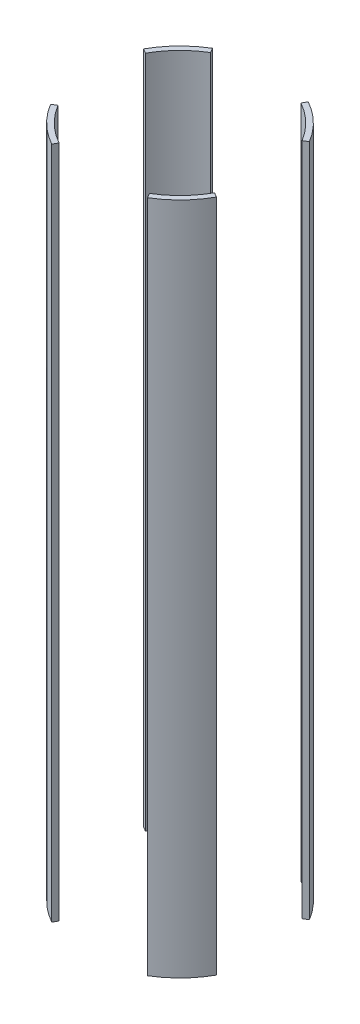
from build123d import *

# Parameters (mm, degrees)
SKETCH2_R               = 88.9
SKETCH2_R_2             = 83.82
BOSS_EXTRUDE1_DEPTH     = 317.5
CUT_EXTRUDE1_DEPTH      = 318.5
CUT_EXTRUDE1_DEPTH_BACK = 318.5


with BuildPart() as part:
    # Sketch2 → Boss-Extrude1 (new body, symmetric)
    with BuildSketch(Plane(origin=(0, 0, 0), x_dir=(1, 0, 0), z_dir=(0, 1, 0))):
        Circle(SKETCH2_R)
        Circle(SKETCH2_R_2, mode=Mode.SUBTRACT)
    extrude(amount=BOSS_EXTRUDE1_DEPTH, both=True)

    # Sketch3 → Cut-Extrude1 (cut, two sides)
    with BuildSketch(Plane(origin=(0, 0, 0), x_dir=(1, 0, 0), z_dir=(0, 1, 0))) as cut_extrude1_sk:
        Polygon((169.661755759, -94.300371224), (0, 0), (169.661755759, 101.677593364), align=None)
        Polygon((0, 0), (53.900027233, 96.974944394), (-58.116685864, 96.974944394), align=None)
        Polygon((-123.741299607, 68.777140945), (-123.741299607, -74.157652604), (0, 0), align=None)
        Polygon((-65.840936026, -118.45858783), (0, 0), (70.991745134, -118.45858783), align=None)
    extrude(amount=CUT_EXTRUDE1_DEPTH, mode=Mode.SUBTRACT)
    extrude(cut_extrude1_sk.sketch, amount=-CUT_EXTRUDE1_DEPTH_BACK, mode=Mode.SUBTRACT)


solid = part.part
